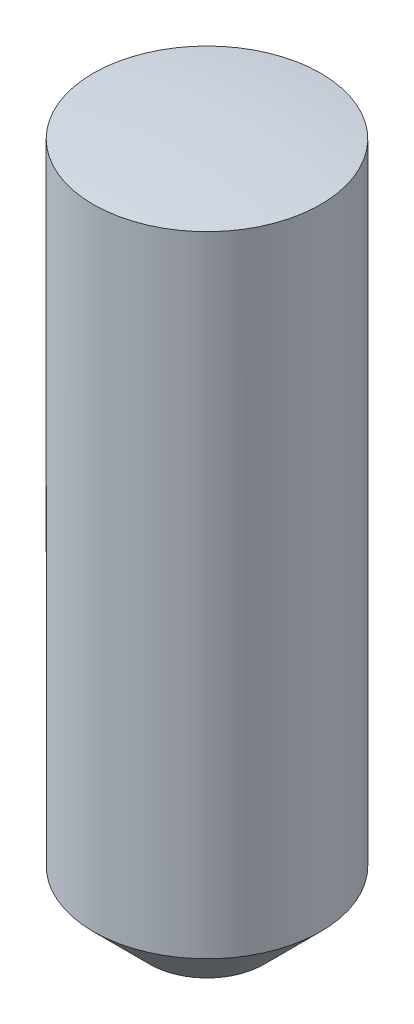
from build123d import *

# Parameters (mm, degrees)
SKETCH1_R                 = 1
BOSS_EXTRUDE_6_10MM_DEPTH = 6.1
F_0_5_X_45_DEG_SIZE       = 0.5


with BuildPart() as part:
    # Sketch1 → Boss-Extrude 6.10mm (new body)
    with BuildSketch(Plane(origin=(0, 0, 0), x_dir=(1, 0, 0), z_dir=(0, 1, 0))):
        Circle(SKETCH1_R)
    extrude(amount=-BOSS_EXTRUDE_6_10MM_DEPTH)

    # 0.5 x 45 deg
    f_0_5_x_45_deg_edges = [part.edges().sort_by_distance(p)[0] for p in [
        (-1, -6.1, 0),
    ]]
    chamfer(f_0_5_x_45_deg_edges, length=F_0_5_X_45_DEG_SIZE)

    # Sketch2 → SR8 (revolve, cut)
    with BuildSketch(Plane.XY):
        with BuildLine():
            Line((0, 2), (-2, 2))
            Line((-2, 2), (-2, -0.254033308))
            ThreePointArc((-2, -0.254033308), (-1.00803434, -0.06376243), (0, 0))
            Line((0, 0), (0, 2))
        make_face()
    revolve(axis=Axis((0, 0, 0), (0, 1, 0)), mode=Mode.SUBTRACT)


solid = part.part
